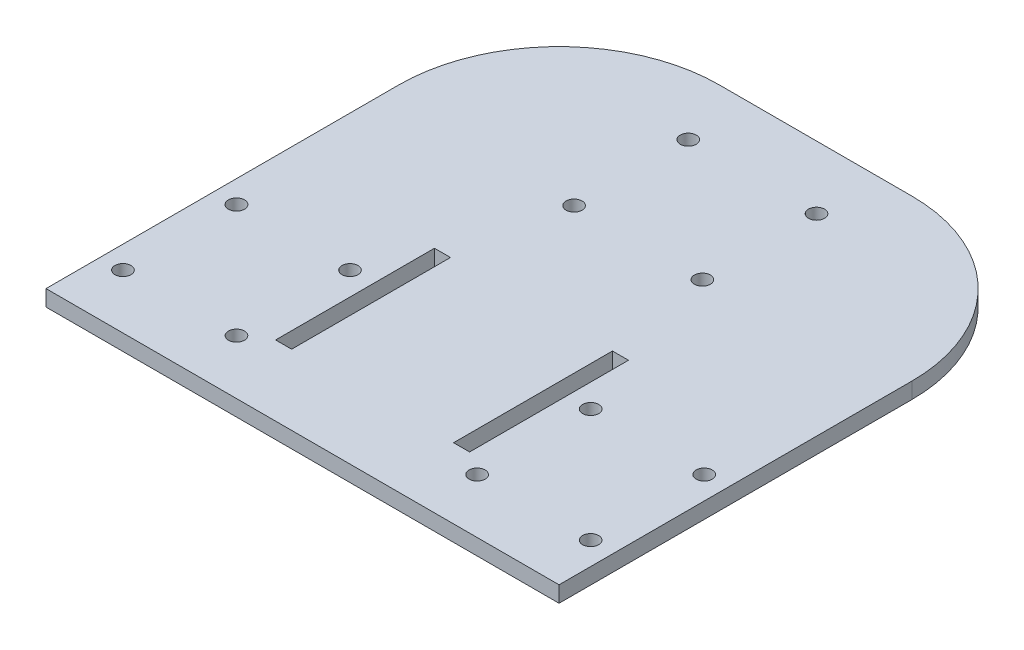
from build123d import *

# Parameters (mm, degrees)
SKETCH1_W           = 203.2
SKETCH1_H           = 203.2
BOSS_EXTRUDE1_DEPTH = 6.35
CUT_EXTRUDE1_DEPTH  = 7.35
SKETCH9_R           = 3.175
SKETCH9_R_2         = 3.160008279
SKETCH9_R_3         = 3.205750029
SKETCH9_W           = 6.35
SKETCH9_H           = 62.924217451
CUT_EXTRUDE2_DEPTH  = 7.35


with BuildPart() as part:
    # Sketch1 → Boss-Extrude1 (new body)
    with BuildSketch(Plane(origin=(0, 0, 0), x_dir=(1, 0, 0), z_dir=(0, 1, 0))):
        Rectangle(SKETCH1_W, SKETCH1_H)
    extrude(amount=BOSS_EXTRUDE1_DEPTH)

    # Sketch2 → Cut-Extrude1 (cut, through all)
    with BuildSketch(Plane(origin=(0, 6.35, 0), x_dir=(1, 0, 0), z_dir=(0, 1, 0))):
        with BuildLine():
            Line((101.6, 38.1), (101.6, 101.6))
            Line((101.6, 101.6), (38.1, 101.6))
            ThreePointArc((38.1, 101.6), (83.001280605, 83.001280605), (101.6, 38.1))
        make_face()
        with BuildLine():
            Line((-38.1, 101.6), (-101.6, 101.6))
            Line((-101.6, 101.6), (-101.6, 38.1))
            ThreePointArc((-101.6, 38.1), (-83.001280605, 83.001280605), (-38.1, 101.6))
        make_face()
    extrude(amount=-CUT_EXTRUDE1_DEPTH, mode=Mode.SUBTRACT)

    # Sketch9 → Cut-Extrude2 (cut, through all)
    with BuildSketch(Plane.XZ):
        with Locations((-25.490256121, -31.45083867)):
            Circle(SKETCH9_R)
        with Locations((25.309743879, -31.45083867)):
            Circle(SKETCH9_R)
        with Locations((-25.490256121, -76.66283867)):
            Circle(SKETCH9_R)
        with Locations((25.309743879, -76.66283867)):
            Circle(SKETCH9_R)
        with Locations((-47.746294791, 80.015705209)):
            Circle(SKETCH9_R)
        with Locations((-92.71, 80.015705209)):
            Circle(SKETCH9_R)
        with Locations((-47.746294791, 35.052)):
            Circle(SKETCH9_R_2)
        with Locations((-92.71, 35.052)):
            Circle(SKETCH9_R_3)
        with Locations((47.565782549, 80.015705209)):
            Circle(SKETCH9_R)
        with Locations((92.529487758, 80.015705209)):
            Circle(SKETCH9_R)
        with Locations((47.565782549, 35.052)):
            Circle(SKETCH9_R)
        with Locations((92.529487758, 35.052)):
            Circle(SKETCH9_R)
        with Locations((-35.33703867, 42.293852605)):
            Rectangle(SKETCH9_W, SKETCH9_H)
        with Locations((35.156526428, 42.293852605)):
            Rectangle(SKETCH9_W, SKETCH9_H)
    extrude(amount=-CUT_EXTRUDE2_DEPTH, mode=Mode.SUBTRACT)


solid = part.part
